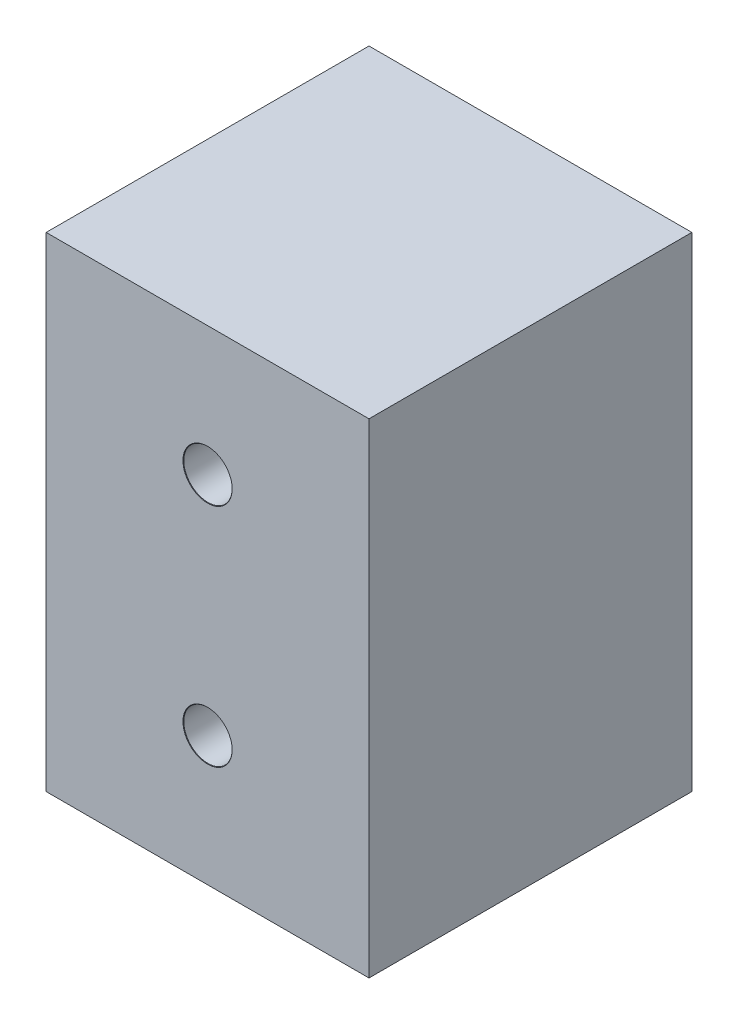
from build123d import *

# Parameters (mm, degrees)
SKETCH1_W                       = 20
SKETCH1_H                       = 20
BOSS_EXTRUDE1_DEPTH             = 30
F_3_0MM_DOWEL_HOLE1_D           = 3
F_3_0MM_DOWEL_HOLE1_DEPTH       = 20
F_3_0MM_DOWEL_HOLE1_CSINK_D     = 3.05
F_3_0MM_DOWEL_HOLE1_CSINK_ANGLE = 90
F_3_0MM_DOWEL_HOLE1_TIP         = 0.901290929
F_3_0MM_DOWEL_HOLE2_D           = 3
F_3_0MM_DOWEL_HOLE2_DEPTH       = 20
F_3_0MM_DOWEL_HOLE2_CSINK_D     = 3.05
F_3_0MM_DOWEL_HOLE2_CSINK_ANGLE = 90
F_3_0MM_DOWEL_HOLE2_TIP         = 0.901290929


with BuildPart() as part:
    # Sketch1 → Boss-Extrude1 (new body)
    with BuildSketch(Plane(origin=(0, 0, 0), x_dir=(1, 0, 0), z_dir=(0, 1, 0))):
        with Locations((10, -10)):
            Rectangle(SKETCH1_W, SKETCH1_H)
    extrude(amount=BOSS_EXTRUDE1_DEPTH)

    # Ø3.0mm Dowel Hole1
    with Locations(Plane(origin=(0, 0, 20), x_dir=(-1, 0, 0), z_dir=(0, 0, 1))):
        with Locations((-10, -8)):
            CounterSinkHole(F_3_0MM_DOWEL_HOLE1_D / 2, F_3_0MM_DOWEL_HOLE1_CSINK_D / 2, depth=F_3_0MM_DOWEL_HOLE1_DEPTH, counter_sink_angle=F_3_0MM_DOWEL_HOLE1_CSINK_ANGLE)
            with Locations((0, 0, -(F_3_0MM_DOWEL_HOLE1_DEPTH + F_3_0MM_DOWEL_HOLE1_TIP / 2))):  # 118° drill point
                Cone(0, F_3_0MM_DOWEL_HOLE1_D / 2, F_3_0MM_DOWEL_HOLE1_TIP, mode=Mode.SUBTRACT)

    # Ø3.0mm Dowel Hole2
    with Locations(Plane.XY.offset(20)):
        with Locations((10, 22)):
            CounterSinkHole(F_3_0MM_DOWEL_HOLE2_D / 2, F_3_0MM_DOWEL_HOLE2_CSINK_D / 2, depth=F_3_0MM_DOWEL_HOLE2_DEPTH, counter_sink_angle=F_3_0MM_DOWEL_HOLE2_CSINK_ANGLE)
            with Locations((0, 0, -(F_3_0MM_DOWEL_HOLE2_DEPTH + F_3_0MM_DOWEL_HOLE2_TIP / 2))):  # 118° drill point
                Cone(0, F_3_0MM_DOWEL_HOLE2_D / 2, F_3_0MM_DOWEL_HOLE2_TIP, mode=Mode.SUBTRACT)


solid = part.part
